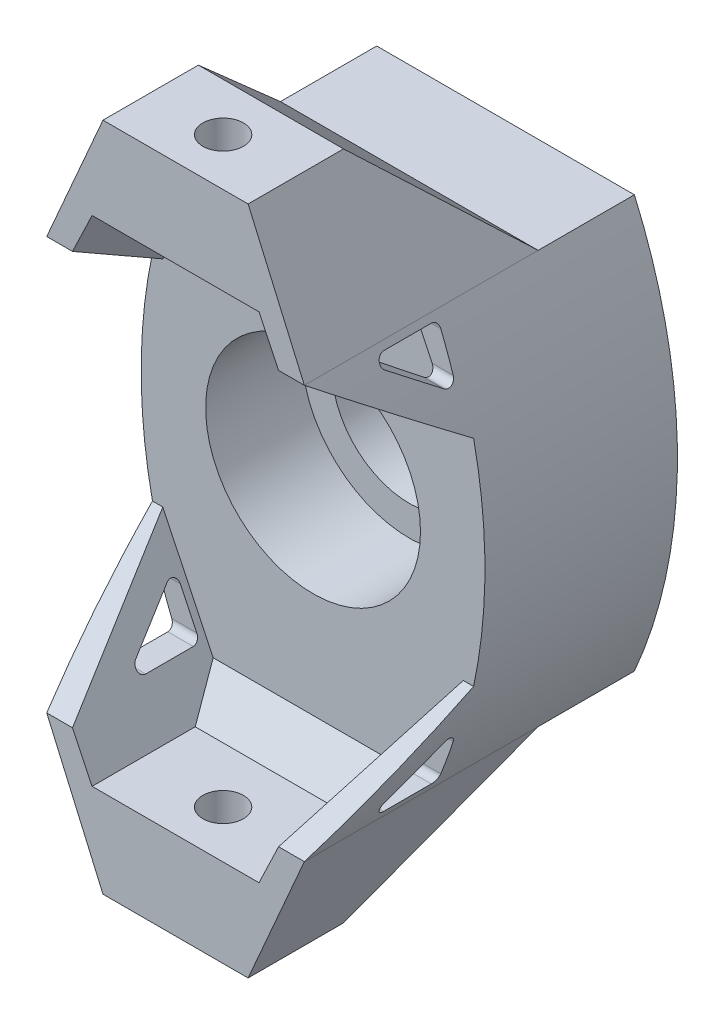
from build123d import *

# Parameters (mm, degrees)
SKETCH1_R               = 7.9375
BOSS_EXTRUDE1_DEPTH     = 7.112
SKETCH2_R               = 5.715
BOSS_EXTRUDE2_DEPTH     = 7.112
BOSS_EXTRUDE3_DEPTH     = 10.16
SKETCH4_R               = 1.5
CUT_EXTRUDE1_DEPTH      = 50.53
CUT_EXTRUDE2_DEPTH      = 23.219226796
BOSS_EXTRUDE5_DEPTH     = 10.16
CUT_EXTRUDE3_DEPTH      = 4.180773204
CUT_EXTRUDE3_DEPTH_BACK = 23.219226796
CUT_EXTRUDE5_DEPTH      = 23.219226896
CUT_EXTRUDE6_DEPTH      = 10.16
BOSS_EXTRUDE6_DEPTH     = 10.16
CUT_EXTRUDE7_DEPTH      = 4.180773304
CUT_EXTRUDE7_DEPTH_BACK = 23.219226896
BOSS_EXTRUDE7_START     = -16.899912
BOSS_EXTRUDE7_DEPTH     = 14.76137


with BuildPart() as part:
    # Sketch1 → Boss-Extrude1 (new body)
    with BuildSketch(Plane.XY):
        with BuildLine():
            ThreePointArc((9.519226796, 15.24), (12.7, 0), (9.519226796, -15.24))
            Line((9.519226796, -15.24), (-9.519226796, -15.24))
            ThreePointArc((-9.519226796, -15.24), (-12.7, 0), (-9.519226796, 15.24))
            Line((-9.519226796, 15.24), (9.519226796, 15.24))
        make_face()
        Circle(SKETCH1_R, mode=Mode.SUBTRACT)
        Polygon((5.362175987, 24.765), (9.519226796, 15.24), (-9.519226796, 15.24), (-5.362175987, 24.765), align=None)
        Polygon((-9.519226796, -15.24), (9.519226796, -15.24), (5.362175987, -24.765), (-5.362175987, -24.765), align=None)
    extrude(amount=BOSS_EXTRUDE1_DEPTH)

    # Sketch2 → Boss-Extrude2 (add)
    with BuildSketch(Plane(origin=(0, 0, 0), x_dir=(-1, 0, 0), z_dir=(0, 0, -1))):
        with BuildLine():
            Line((9.519226796, -15.24), (-9.519226796, -15.24))
            ThreePointArc((-9.519226796, -15.24), (-12.7, 0), (-9.519226796, 15.24))
            Line((-9.519226796, 15.24), (9.519226796, 15.24))
            ThreePointArc((9.519226796, 15.24), (12.7, 0), (9.519226796, -15.24))
        make_face()
        Circle(SKETCH2_R, mode=Mode.SUBTRACT)
    extrude(amount=BOSS_EXTRUDE2_DEPTH)

    # Sketch3 → Boss-Extrude3 (add)
    with BuildSketch(Plane.XY.offset(7.112)):
        Polygon((5.362175987, 24.765), (9.519226796, 15.24), (-9.519226796, 15.24), (-5.362175987, 24.765), align=None)
        Polygon((5.362175987, -24.765), (9.519226796, -15.24), (-9.519226796, -15.24), (-5.362175987, -24.765), align=None)
    extrude(amount=BOSS_EXTRUDE3_DEPTH)

    # Sketch4 → Cut-Extrude1 (cut, through all)
    with BuildSketch(Plane(origin=(0, 24.765, 0), x_dir=(1, 0, 0), z_dir=(0, 1, 0))):
        with Locations((0, -13.756694386)):
            Circle(SKETCH4_R)
    extrude(amount=-CUT_EXTRUDE1_DEPTH, mode=Mode.SUBTRACT)

    # Sketch5 → Cut-Extrude2 (cut, through all)
    with BuildSketch(Plane.ZY.offset(9.519226796)):
        Polygon((0, 15.24), (10.224694386, 24.765), (0, 24.765), align=None)
        Polygon((17.272, 15.24), (17.272, 18.26514), (9.652, 18.26514), (7.112, 15.72514), (7.112, 15.24), align=None)
    extrude(amount=-CUT_EXTRUDE2_DEPTH, mode=Mode.SUBTRACT)

    # Sketch6 → Boss-Extrude5 (add)
    with BuildSketch(Plane.XY.offset(7.112)):
        with BuildLine():
            Line((-7.612509174, 15.24), (-9.519226796, 15.24))
            ThreePointArc((-9.519226796, 15.24), (-10.875837369, 11.647902093), (-11.864005337, 7.9375))
            Line((-11.864005337, 7.9375), (-11.102005337, 7.9375))
            Line((-11.102005337, 7.9375), (-7.612509174, 15.24))
        make_face()
        Polygon((-9.307494341, 15.72514), (-9.519226796, 15.24), (-7.612509174, 15.24), (-7.380685255, 15.72514), align=None)
        Polygon((-8.198947459, 18.26514), (-9.307494341, 15.72514), (-7.380685255, 15.72514), (-6.166947459, 18.26514), align=None)
        Polygon((8.198947459, 18.26514), (6.166947459, 18.26514), (7.380685255, 15.72514), (9.307494341, 15.72514), align=None)
        Polygon((7.380685255, 15.72514), (7.612509174, 15.24), (9.519226796, 15.24), (9.307494341, 15.72514), align=None)
        with BuildLine():
            Line((9.519226796, 15.24), (7.612509174, 15.24))
            Line((7.612509174, 15.24), (11.102005337, 7.9375))
            Line((11.102005337, 7.9375), (11.864005337, 7.9375))
            ThreePointArc((11.864005337, 7.9375), (10.875837369, 11.647902093), (9.519226796, 15.24))
        make_face()
    extrude(amount=BOSS_EXTRUDE5_DEPTH)

    # Sketch7 → Cut-Extrude3 (cut, two sides)
    with BuildSketch(Plane.ZY.offset(9.519226796)) as cut_extrude3_sk:
        Polygon((7.112, 7.9375), (17.272, 15.24), (17.272, 7.9375), align=None)
        with BuildLine():
            Line((8.403818024, 11.307371095), (11.919117111, 13.833992314))
            ThreePointArc((11.919117111, 13.833992314), (12.103221267, 14.39329083), (11.627299087, 14.74))
            Line((11.627299087, 14.74), (8.112, 14.74))
            ThreePointArc((8.112, 14.74), (7.758446609, 14.593553391), (7.612, 14.24))
            Line((7.612, 14.24), (7.612, 11.713378781))
            ThreePointArc((7.612, 11.713378781), (7.883865185, 11.268457995), (8.403818024, 11.307371095))
        make_face()
    extrude(amount=CUT_EXTRUDE3_DEPTH, mode=Mode.SUBTRACT)
    extrude(cut_extrude3_sk.sketch, amount=-CUT_EXTRUDE3_DEPTH_BACK, mode=Mode.SUBTRACT)

    # Sketch9 → Cut-Extrude5 (cut, through all)
    with BuildSketch(Plane.ZY.offset(9.519226796)):
        Polygon((0, -24.765), (10.224694386, -24.765), (0, -15.24), align=None)
    extrude(amount=-CUT_EXTRUDE5_DEPTH, mode=Mode.SUBTRACT)

    # Sketch8 → Cut-Extrude6 (cut)
    with BuildSketch(Plane.XY.offset(17.272)):
        Polygon((7.612509174, -15.24), (-7.612509174, -15.24), (-6.166947459, -18.26514), (6.166947459, -18.26514), align=None)
    extrude(amount=-CUT_EXTRUDE6_DEPTH, mode=Mode.SUBTRACT)

    # Sketch10 → Boss-Extrude6 (add)
    with BuildSketch(Plane.XY.offset(7.112)):
        with BuildLine():
            Line((-9.519226796, -15.24), (-7.612509174, -15.24))
            Line((-7.612509174, -15.24), (-11.102005337, -7.9375))
            Line((-11.102005337, -7.9375), (-11.864005337, -7.9375))
            ThreePointArc((-11.864005337, -7.9375), (-10.875837369, -11.647902093), (-9.519226796, -15.24))
        make_face()
        with BuildLine():
            Line((7.612509174, -15.24), (9.519226796, -15.24))
            ThreePointArc((9.519226796, -15.24), (10.875837369, -11.647902093), (11.864005337, -7.9375))
            Line((11.864005337, -7.9375), (11.102005337, -7.9375))
            Line((11.102005337, -7.9375), (7.612509174, -15.24))
        make_face()
    extrude(amount=BOSS_EXTRUDE6_DEPTH)

    # Sketch11 → Cut-Extrude7 (cut, two sides)
    with BuildSketch(Plane.ZY.offset(9.519226796)) as cut_extrude7_sk:
        Polygon((17.272, -15.24), (17.272, -7.9375), (7.112, -7.9375), align=None)
        with BuildLine():
            ThreePointArc((8.112, -14.74), (7.758446609, -14.593553391), (7.612, -14.24))
            Line((7.612, -14.24), (7.612, -11.713378781))
            ThreePointArc((7.612, -11.713378781), (7.883865185, -11.268457995), (8.403818024, -11.307371095))
            Line((8.403818024, -11.307371095), (11.919117111, -13.833992314))
            ThreePointArc((11.919117111, -13.833992314), (12.103221267, -14.39329083), (11.627299087, -14.74))
            Line((11.627299087, -14.74), (8.112, -14.74))
        make_face()
    extrude(amount=CUT_EXTRUDE7_DEPTH, mode=Mode.SUBTRACT)
    extrude(cut_extrude7_sk.sketch, amount=-CUT_EXTRUDE7_DEPTH_BACK, mode=Mode.SUBTRACT)

    # Sketch12 → Boss-Extrude7 (add)
    with BuildSketch(Plane.ZY.offset(9.519226796).offset(BOSS_EXTRUDE7_START)):
        Polygon((7.112, -18.26514), (7.112, -15.72514), (9.652, -18.26514), align=None)
    extrude(amount=BOSS_EXTRUDE7_DEPTH)


solid = part.part
